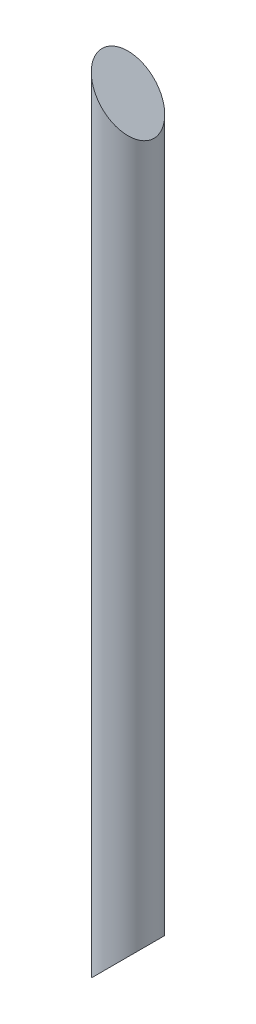
from build123d import *

# Parameters (mm, degrees)
SKETCH1_R               = 31.75
BOSS_EXTRUDE3_DEPTH     = 850.9
BOSS_EXTRUDE4_START     = -63.5
SKETCH1_3_R             = 31.75
BOSS_EXTRUDE4_DEPTH     = 63.5
SKETCH5_R               = 31.75
BOSS_EXTRUDE5_DEPTH     = 63.5
CUT_EXTRUDE7_DEPTH      = 96.774
CUT_EXTRUDE7_DEPTH_BACK = 96.774


with BuildPart() as part:
    # Sketch1 → Boss-Extrude3 (new body)
    with BuildSketch(Plane(origin=(0, 0, 0), x_dir=(1, 0, 0), z_dir=(0, 1, 0))):
        Circle(SKETCH1_R)
    extrude(amount=BOSS_EXTRUDE3_DEPTH)

    # Sketch1_3 → Boss-Extrude4 (add)
    with BuildSketch(Plane(origin=(0, 0, 0), x_dir=(1, 0, 0), z_dir=(0, 1, 0)).offset(BOSS_EXTRUDE4_START)):
        Circle(SKETCH1_3_R)
    extrude(amount=BOSS_EXTRUDE4_DEPTH)

    # Sketch5 → Boss-Extrude5 (add)
    with BuildSketch(Plane(origin=(0, 850.9, 0), x_dir=(1, 0, 0), z_dir=(0, 1, 0))):
        Circle(SKETCH5_R)
    extrude(amount=BOSS_EXTRUDE5_DEPTH)

    # Sketch2 → Cut-Extrude7 (cut, two sides: drawn at the far end of the back side and taken through both)
    with BuildSketch(Plane.XY.offset(-CUT_EXTRUDE7_DEPTH_BACK)):
        Polygon((-31.75, 914.4), (31.75, 850.9), (31.75, 914.4), align=None)
        Polygon((31.75, -63.5), (31.75, 0), (-31.75, -63.5), align=None)
    extrude(amount=CUT_EXTRUDE7_DEPTH + CUT_EXTRUDE7_DEPTH_BACK, mode=Mode.SUBTRACT)


solid = part.part
